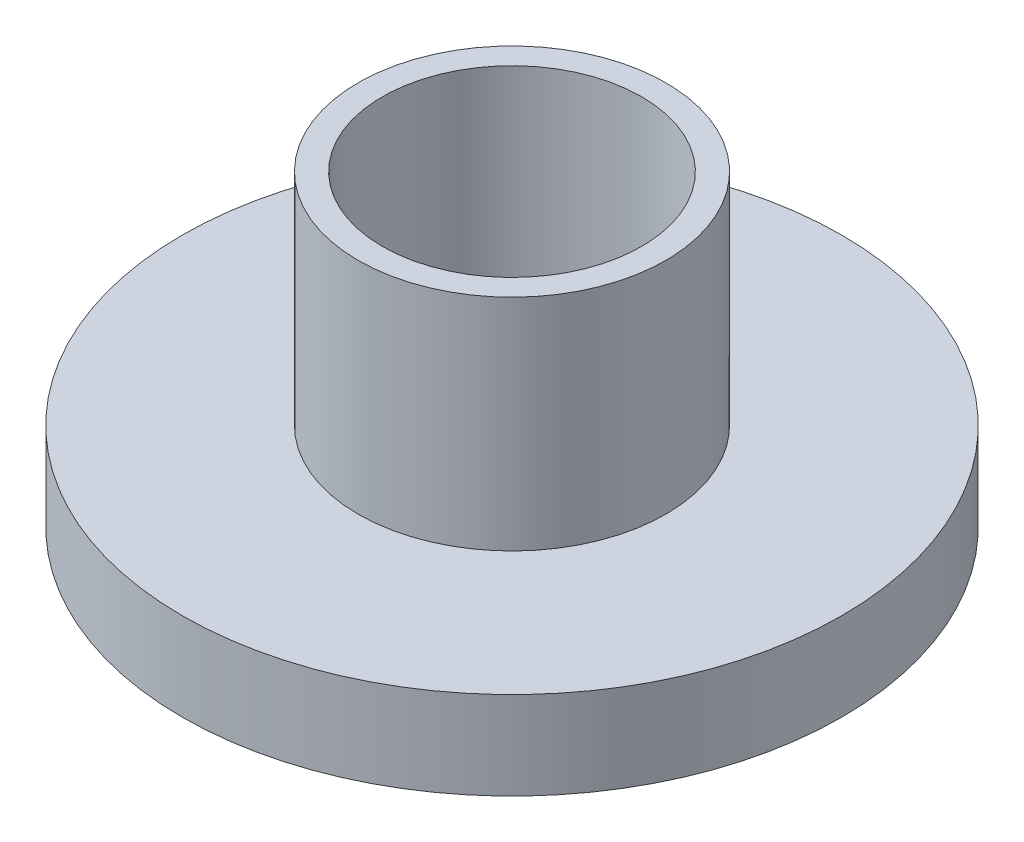
from build123d import *

# Parameters (mm, degrees)
SKETCH9_R           = 7.5
BOSS_EXTRUDE4_DEPTH = 2
SKETCH10_R          = 3.5
BOSS_EXTRUDE5_DEPTH = 5
SKETCH11_R          = 2.95
CUT_EXTRUDE3_DEPTH  = 14


with BuildPart() as part:
    # Sketch9 → Boss-Extrude4 (new body)
    with BuildSketch(Plane(origin=(0, 0, 0), x_dir=(1, 0, 0), z_dir=(0, 1, 0))):
        Circle(SKETCH9_R)
    extrude(amount=BOSS_EXTRUDE4_DEPTH)

    # Sketch10 → Boss-Extrude5 (add)
    with BuildSketch(Plane(origin=(0, 2, 0), x_dir=(1, 0, 0), z_dir=(0, 1, 0))):
        Circle(SKETCH10_R)
    extrude(amount=BOSS_EXTRUDE5_DEPTH)

    # Sketch11 → Cut-Extrude3 (cut)
    with BuildSketch(Plane(origin=(0, 7, 0), x_dir=(1, 0, 0), z_dir=(0, 1, 0))):
        Circle(SKETCH11_R)
    extrude(amount=-CUT_EXTRUDE3_DEPTH, mode=Mode.SUBTRACT)


solid = part.part
